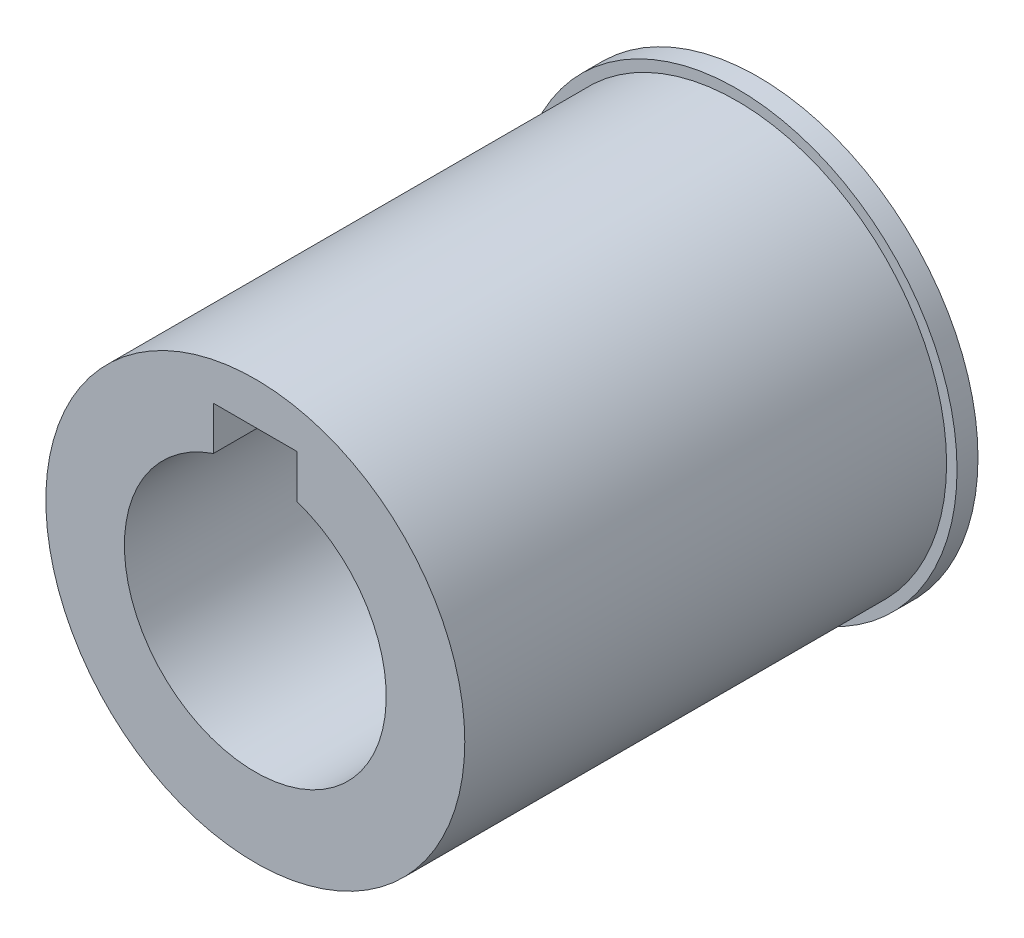
from build123d import *

# Parameters (mm, degrees)
SKETCH1_R           = 21
BOSS_EXTRUDE1_DEPTH = 2
SKETCH2_R           = 20
BOSS_EXTRUDE2_DEPTH = 46
SKETCH3_R           = 12.5
CUT_EXTRUDE1_DEPTH  = 49
SKETCH4_W           = 8
SKETCH4_H           = 7
CUT_EXTRUDE2_DEPTH  = 48


with BuildPart() as part:
    # Sketch1 → Boss-Extrude1 (new body)
    with BuildSketch(Plane.XY):
        Circle(SKETCH1_R)
    extrude(amount=BOSS_EXTRUDE1_DEPTH)

    # Sketch2 → Boss-Extrude2 (add)
    with BuildSketch(Plane.XY.offset(2)):
        Circle(SKETCH2_R)
    extrude(amount=BOSS_EXTRUDE2_DEPTH)

    # Sketch3 → Cut-Extrude1 (cut, through all)
    with BuildSketch(Plane(origin=(0, 0, 0), x_dir=(-1, 0, 0), z_dir=(0, 0, -1))):
        Circle(SKETCH3_R)
    extrude(amount=-CUT_EXTRUDE1_DEPTH, mode=Mode.SUBTRACT)

    # Sketch4 → Cut-Extrude2 (cut)
    with BuildSketch(Plane(origin=(0, 0, 0), x_dir=(-1, 0, 0), z_dir=(0, 0, -1))):
        with Locations((0, 12.5)):
            Rectangle(SKETCH4_W, SKETCH4_H)
    extrude(amount=-CUT_EXTRUDE2_DEPTH, mode=Mode.SUBTRACT)


solid = part.part
